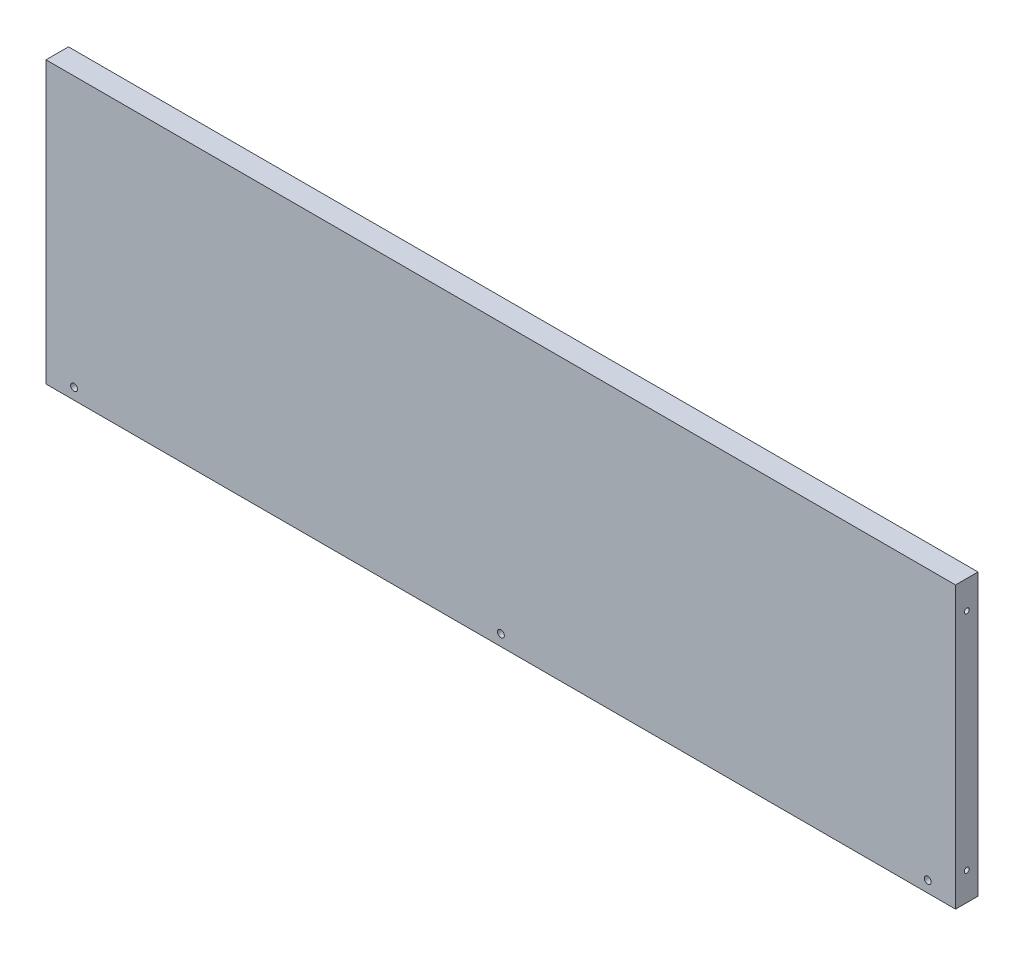
from build123d import *

# Parameters (mm, degrees)
SKETCH1_W                                      = 324
SKETCH1_H                                      = 100
BOSS_EXTRUDE1_DEPTH                            = 8
CBORE_FOR_2_SOCKET_HEAD_CAP_SCREW1_D           = 2.4384
CBORE_FOR_2_SOCKET_HEAD_CAP_SCREW1_CBORE_D     = 4.7625
CBORE_FOR_2_SOCKET_HEAD_CAP_SCREW1_CBORE_DEPTH = 2.1844
F_2_56_TAPPED_HOLE1_D                          = 1.778
F_2_56_TAPPED_HOLE1_DEPTH                      = 15
F_2_56_TAPPED_HOLE1_TIP                        = 0.53416509
F_2_56_TAPPED_HOLE2_D                          = 1.778
F_2_56_TAPPED_HOLE2_DEPTH                      = 15
F_2_56_TAPPED_HOLE2_TIP                        = 0.53416509
SKETCH10_W                                     = 8
SKETCH10_H                                     = 100
CUT_EXTRUDE1_DEPTH                             = 0.1


with BuildPart() as part:
    # Sketch1 → Boss-Extrude1 (new body)
    with BuildSketch(Plane.XY):
        with Locations((162, 50)):
            Rectangle(SKETCH1_W, SKETCH1_H)
    extrude(amount=BOSS_EXTRUDE1_DEPTH)

    # CBORE for #2 Socket Head Cap Screw1 (through all)
    with Locations(Plane(origin=(0, 0, 0), x_dir=(-1, 0, 0), z_dir=(0, 0, -1))):
        with Locations((-314, 4), (-10, 4), (-162, 4)):
            CounterBoreHole(CBORE_FOR_2_SOCKET_HEAD_CAP_SCREW1_D / 2, CBORE_FOR_2_SOCKET_HEAD_CAP_SCREW1_CBORE_D / 2, CBORE_FOR_2_SOCKET_HEAD_CAP_SCREW1_CBORE_DEPTH)

    # #2-56 Tapped Hole1
    with Locations(Plane(origin=(324, 0, 0), x_dir=(0, 0, -1), z_dir=(1, 0, 0))):
        with Locations((-4, 90), (-4, 10)):
            Hole(F_2_56_TAPPED_HOLE1_D / 2, depth=F_2_56_TAPPED_HOLE1_DEPTH)
            with Locations((0, 0, -(F_2_56_TAPPED_HOLE1_DEPTH + F_2_56_TAPPED_HOLE1_TIP / 2))):  # 118° drill point
                Cone(0, F_2_56_TAPPED_HOLE1_D / 2, F_2_56_TAPPED_HOLE1_TIP, mode=Mode.SUBTRACT)

    # #2-56 Tapped Hole2
    with Locations(Plane.ZY):
        with Locations((4, 90), (4, 10)):
            Hole(F_2_56_TAPPED_HOLE2_D / 2, depth=F_2_56_TAPPED_HOLE2_DEPTH)
            with Locations((0, 0, -(F_2_56_TAPPED_HOLE2_DEPTH + F_2_56_TAPPED_HOLE2_TIP / 2))):  # 118° drill point
                Cone(0, F_2_56_TAPPED_HOLE2_D / 2, F_2_56_TAPPED_HOLE2_TIP, mode=Mode.SUBTRACT)

    # Sketch10 → Cut-Extrude1 (cut)
    with BuildSketch(Plane(origin=(324, 0, 0), x_dir=(0, 0, -1), z_dir=(1, 0, 0))):
        with Locations((-4, 50)):
            Rectangle(SKETCH10_W, SKETCH10_H)
    extrude(amount=-CUT_EXTRUDE1_DEPTH, mode=Mode.SUBTRACT)


solid = part.part
